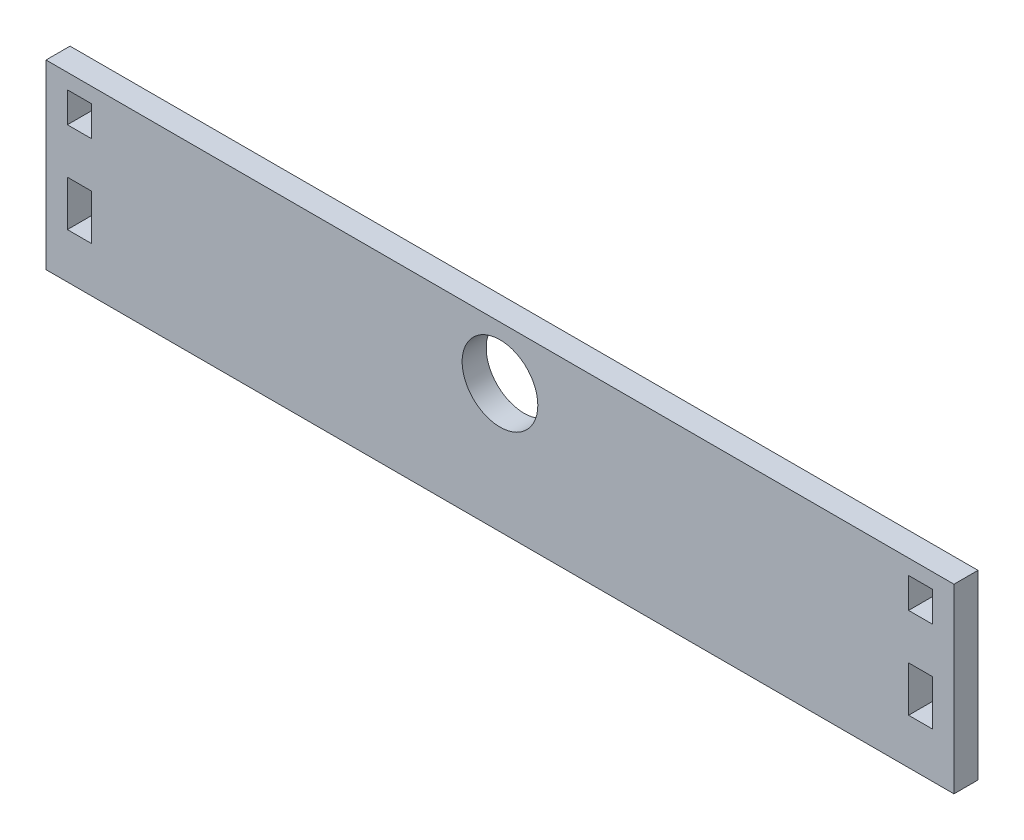
from build123d import *

# Parameters (mm, degrees)
SKETCH1_W        = 60
SKETCH1_H        = 12
SKETCH1_W_2      = 1.5875
SKETCH1_H_2      = 3
SKETCH1_H_3      = 2
EXTRUSION1_DEPTH = 1.5875
SKETCH2_R        = 2.5
EXTRUSION2_DEPTH = 1.5875


with BuildPart() as part:
    # Sketch1 → Extrusion1 (new body)
    with BuildSketch(Plane.XY):
        with Locations((27, 5)):
            Rectangle(SKETCH1_W, SKETCH1_H)
        with Locations((-0.79375, 3.5)):
            Rectangle(SKETCH1_W_2, SKETCH1_H_2, mode=Mode.SUBTRACT)
        with Locations((-0.79375, 9)):
            Rectangle(SKETCH1_W_2, SKETCH1_H_3, mode=Mode.SUBTRACT)
        with Locations((54.79375, 9)):
            Rectangle(SKETCH1_W_2, SKETCH1_H_3, mode=Mode.SUBTRACT)
        with Locations((54.79375, 3.5)):
            Rectangle(SKETCH1_W_2, SKETCH1_H_2, mode=Mode.SUBTRACT)
    extrude(amount=EXTRUSION1_DEPTH)

    # Sketch2 → Extrusion2 (cut)
    with BuildSketch(Plane.XY.offset(1.5875)):
        with Locations((27, 7.489892181)):
            Circle(SKETCH2_R)
    extrude(amount=-EXTRUSION2_DEPTH, mode=Mode.SUBTRACT)


solid = part.part
